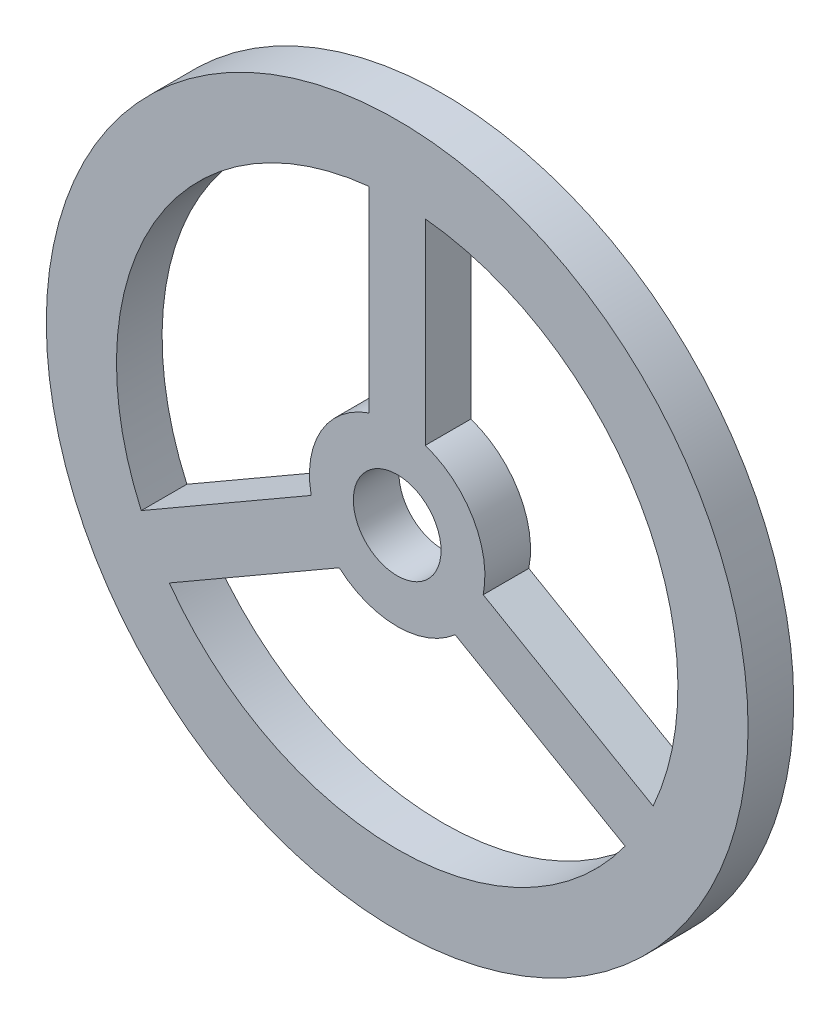
from build123d import *

# Parameters (mm, degrees)
ESQUISSE1_R             = 10
BOSS_EXTRU_1_DEPTH      = 1.3
ENL_V_MAT_EXTRU_1_DEPTH = 2.3
ESQUISSE3_R             = 1.25
ENL_V_MAT_EXTRU_2_DEPTH = 2.3


with BuildPart() as part:
    # Esquisse1 → Boss.-Extru.1 (new body)
    with BuildSketch(Plane.XY):
        Circle(ESQUISSE1_R)
    extrude(amount=BOSS_EXTRU_1_DEPTH)

    # Esquisse2 → Enlèv. mat.-Extru.1 (cut, through all)
    with BuildSketch(Plane.XY.offset(1.3)):
        with BuildLine():
            Line((-7.293475176, -3.287129425), (-2.45121915, -0.491451605))
            ThreePointArc((-2.45121915, -0.491451605), (-2.165063509, 1.25), (-0.8, 2.368543856))
            Line((-0.8, 2.368543856), (-0.8, 7.959899497))
            ThreePointArc((-0.8, 7.959899497), (-6.92820323, 4), (-7.293475176, -3.287129425))
        make_face()
        with BuildLine():
            Line((-6.493475176, -4.672770071), (-1.65121915, -1.877092251))
            ThreePointArc((-1.65121915, -1.877092251), (0, -2.5), (1.65121915, -1.877092251))
            Line((1.65121915, -1.877092251), (6.493475176, -4.672770071))
            ThreePointArc((6.493475176, -4.672770071), (0, -8), (-6.493475176, -4.672770071))
        make_face()
        with BuildLine():
            Line((2.45121915, -0.491451605), (7.293475176, -3.287129425))
            ThreePointArc((7.293475176, -3.287129425), (6.92820323, 4), (0.8, 7.959899497))
            Line((0.8, 7.959899497), (0.8, 2.368543856))
            ThreePointArc((0.8, 2.368543856), (2.165063509, 1.25), (2.45121915, -0.491451605))
        make_face()
    extrude(amount=-ENL_V_MAT_EXTRU_1_DEPTH, mode=Mode.SUBTRACT)

    # Esquisse3 → Enlèv. mat.-Extru.2 (cut, through all)
    with BuildSketch(Plane.XY.offset(1.3)):
        Circle(ESQUISSE3_R)
    extrude(amount=-ENL_V_MAT_EXTRU_2_DEPTH, mode=Mode.SUBTRACT)


solid = part.part
